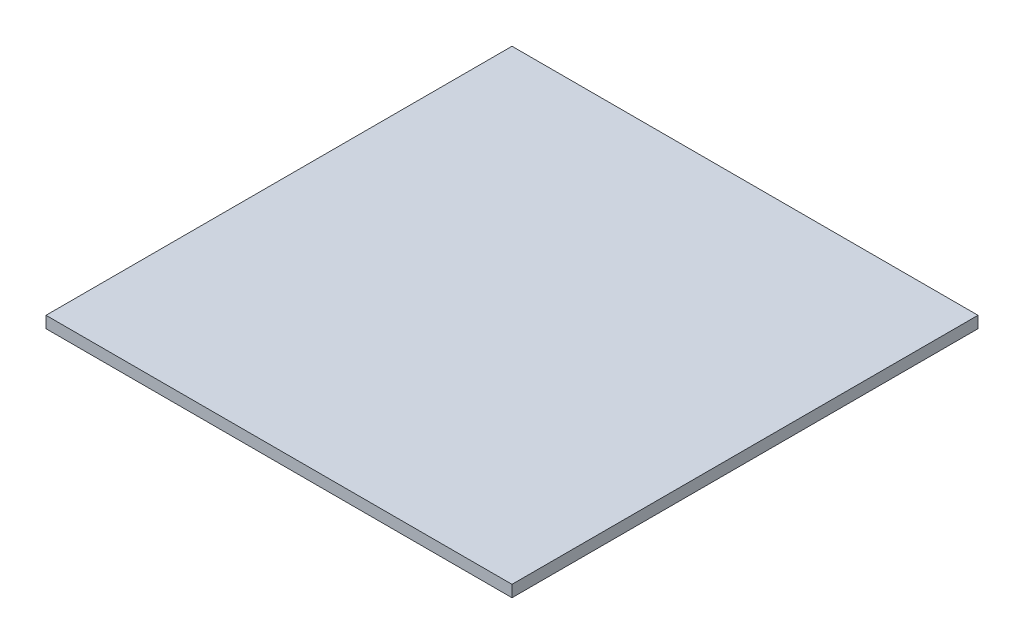
from build123d import *

# Parameters (mm, degrees)
CROQUIS1_W              = 30
CROQUIS1_H              = 80
SALIENTE_EXTRUIR1_DEPTH = 2
CROQUIS2_W              = 80
CROQUIS2_H              = 2
SALIENTE_EXTRUIR2_DEPTH = 50


with BuildPart() as part:
    # Croquis1 → Saliente-Extruir1 (new body)
    with BuildSketch(Plane(origin=(0, 0, 0), x_dir=(1, 0, 0), z_dir=(0, 1, 0))):
        Rectangle(CROQUIS1_W, CROQUIS1_H)
    extrude(amount=SALIENTE_EXTRUIR1_DEPTH)

    # Croquis2 → Saliente-Extruir2 (add)
    with BuildSketch(Plane.ZY.offset(15)):
        with Locations((0, 1)):
            Rectangle(CROQUIS2_W, CROQUIS2_H)
    extrude(amount=SALIENTE_EXTRUIR2_DEPTH)


solid = part.part
